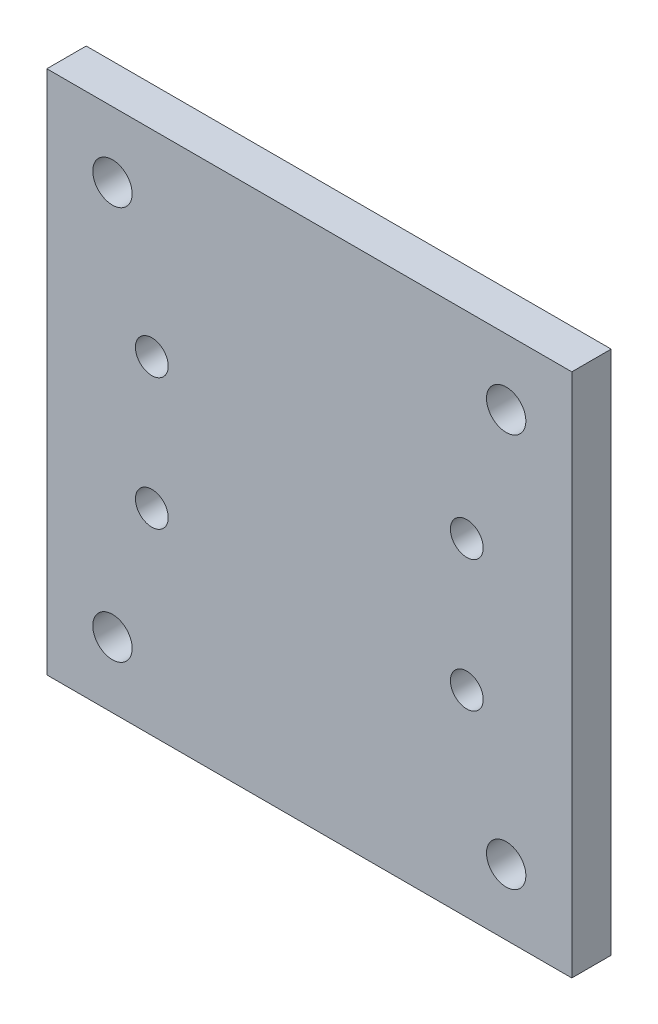
from build123d import *

# Parameters (mm, degrees)
ESQUISSE1_W        = 40
ESQUISSE1_H        = 40
ESQUISSE1_R        = 1.5
ESQUISSE1_R_2      = 1.25
BOSS_EXTRU_1_DEPTH = 3


with BuildPart() as part:
    # Esquisse1 → Boss.-Extru.1 (new body)
    with BuildSketch(Plane.XY):
        Rectangle(ESQUISSE1_W, ESQUISSE1_H)
        with Locations((-15, 15)):
            Circle(ESQUISSE1_R, mode=Mode.SUBTRACT)
        with Locations((15, 15)):
            Circle(ESQUISSE1_R, mode=Mode.SUBTRACT)
        with Locations((15, -15)):
            Circle(ESQUISSE1_R, mode=Mode.SUBTRACT)
        with Locations((-15, -15)):
            Circle(ESQUISSE1_R, mode=Mode.SUBTRACT)
        with Locations((-12, 5)):
            Circle(ESQUISSE1_R_2, mode=Mode.SUBTRACT)
        with Locations((-12, -5)):
            Circle(ESQUISSE1_R_2, mode=Mode.SUBTRACT)
        with Locations((12, -5)):
            Circle(ESQUISSE1_R_2, mode=Mode.SUBTRACT)
        with Locations((12, 5)):
            Circle(ESQUISSE1_R_2, mode=Mode.SUBTRACT)
    extrude(amount=BOSS_EXTRU_1_DEPTH)


solid = part.part
